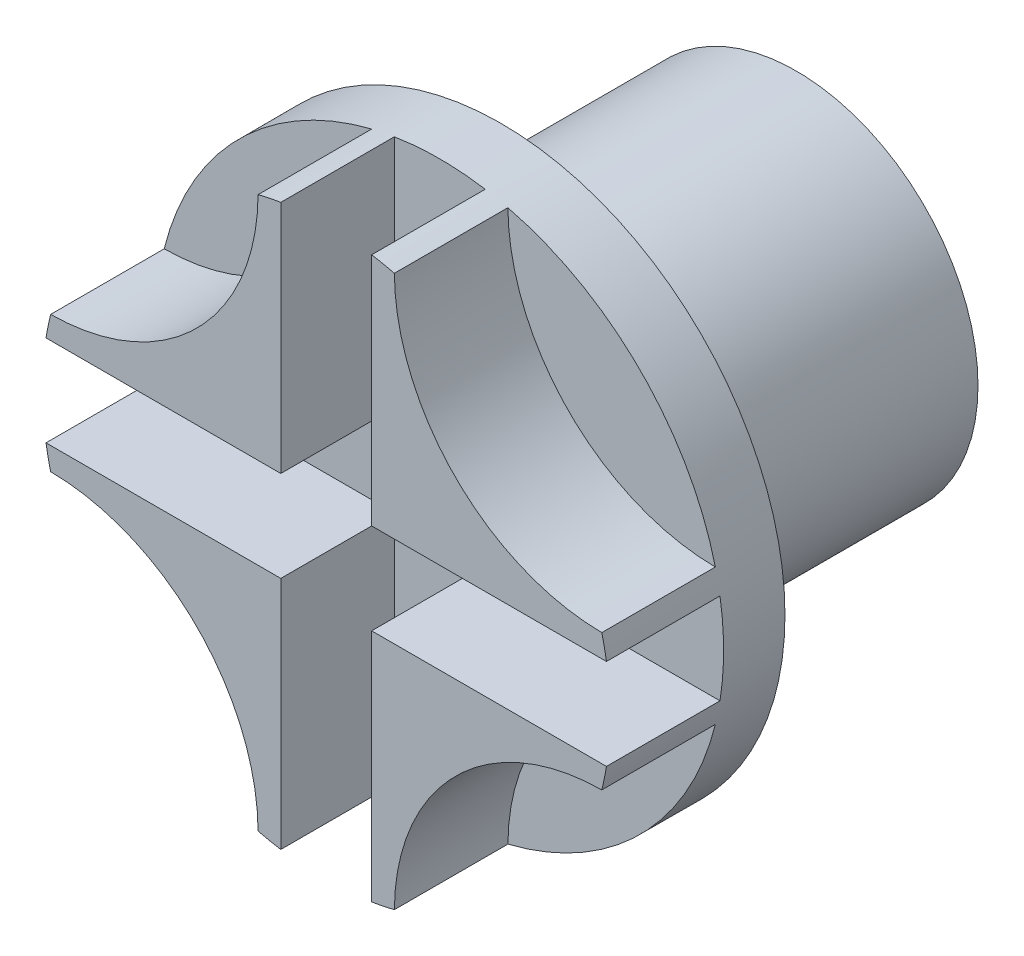
from build123d import *

# Parameters (mm, degrees)
CROQUIS1_R              = 12.5
SALIENTE_EXTRUIR1_DEPTH = 2.7
SALIENTE_EXTRUIR2_START = 2.7
SALIENTE_EXTRUIR2_DEPTH = 5
CROQUIS2_R              = 8
SALIENTE_EXTRUIR3_DEPTH = 13


with BuildPart() as part:
    # Croquis1 → Saliente-Extruir1 (new body)
    with BuildSketch(Plane.XY):
        Circle(CROQUIS1_R)
    extrude(amount=SALIENTE_EXTRUIR1_DEPTH)

    # Croquis1_3 → Saliente-Extruir2 (add)
    with BuildSketch(Plane.XY.offset(SALIENTE_EXTRUIR2_START)):
        with BuildLine():
            Line((-2, 2), (-2, 12.338962679))
            ThreePointArc((-2, 12.338962679), (-2.502086086, 12.247022708), (-3, 12.1346611))
            ThreePointArc((-3, 12.1346611), (-5.694387223, 5.694387223), (-12.1346611, 3))
            ThreePointArc((-12.1346611, 3), (-12.247022708, 2.502086086), (-12.338962679, 2))
            Line((-12.338962679, 2), (-2, 2))
        make_face()
        with BuildLine():
            ThreePointArc((3, 12.1346611), (2.502086086, 12.247022708), (2, 12.338962679))
            Line((2, 12.338962679), (2, 2))
            Line((2, 2), (12.338962679, 2))
            ThreePointArc((12.338962679, 2), (12.247022708, 2.502086086), (12.1346611, 3))
            ThreePointArc((12.1346611, 3), (5.694387223, 5.694387223), (3, 12.1346611))
        make_face()
        with BuildLine():
            Line((12.338962679, -2), (2, -2))
            Line((2, -2), (2, -12.338962679))
            ThreePointArc((2, -12.338962679), (2.502086086, -12.247022708), (3, -12.1346611))
            ThreePointArc((3, -12.1346611), (5.694387223, -5.694387223), (12.1346611, -3))
            ThreePointArc((12.1346611, -3), (12.247022708, -2.502086086), (12.338962679, -2))
        make_face()
        with BuildLine():
            Line((-2, -12.338962679), (-2, -2))
            Line((-2, -2), (-12.338962679, -2))
            ThreePointArc((-12.338962679, -2), (-12.247022708, -2.502086086), (-12.1346611, -3))
            ThreePointArc((-12.1346611, -3), (-5.694387223, -5.694387223), (-3, -12.1346611))
            ThreePointArc((-3, -12.1346611), (-2.502086086, -12.247022708), (-2, -12.338962679))
        make_face()
    extrude(amount=SALIENTE_EXTRUIR2_DEPTH)

    # Croquis2 → Saliente-Extruir3 (add)
    with BuildSketch(Plane(origin=(0, 0, 0), x_dir=(-1, 0, 0), z_dir=(0, 0, -1))):
        Circle(CROQUIS2_R)
    extrude(amount=SALIENTE_EXTRUIR3_DEPTH)


solid = part.part
